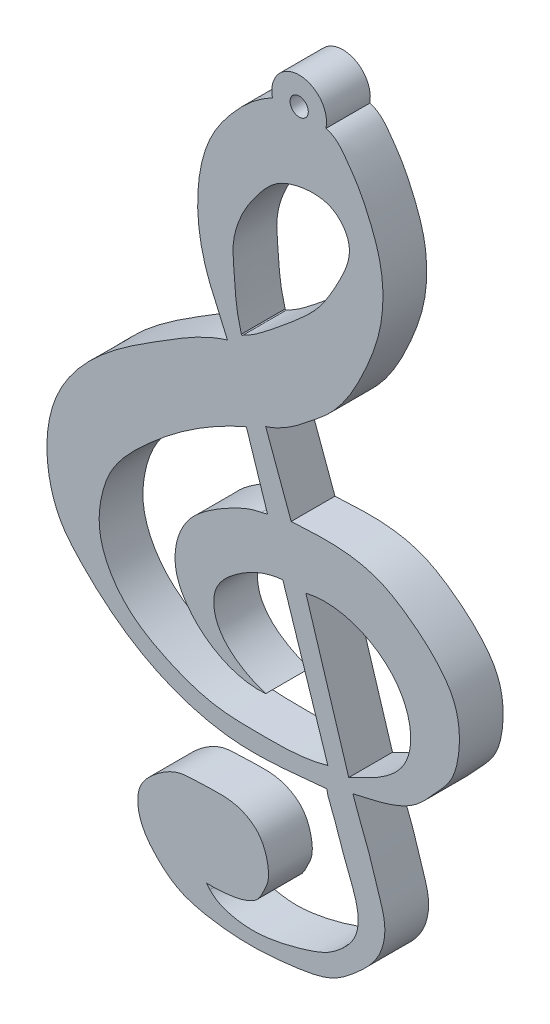
from build123d import *

# Parameters (mm, degrees)
CROQUIS1_R              = 0.5
SALIENTE_EXTRUIR1_DEPTH = 2.4


with BuildPart() as part:
    # Croquis1 → Saliente-Extruir1 (new body)
    with BuildSketch(Plane.XY):
        with BuildLine():
            add(Edge.make_bspline(
                [(-73.382843904, 21.485172649), (-72.816279322, 21.352562277), (-72.290048161, 20.617939926), (-71.563359458, 19.572554368), (-70.955369846, 18.303271377), (-70.180325761, 16.279733813), (-70.210087208, 13.6244299), (-71.118438702, 11.274052597), (-72.034700283, 9.43128208), (-73.060953827, 8.093199889), (-74.176463418, 7.211487575), (-75.245307097, 6.341435028), (-76.105343924, 5.854934057), (-76.688929455, 5.678784709)],
                knots=[0, 0, 0, 0, 0.082720072, 0.13560082, 0.197595917, 0.299487219, 0.46892434, 0.591754444, 0.687028642, 0.786865301, 0.848882337, 0.906336095, 1, 1, 1, 1], degree=3))
            Line((-76.688929455, 5.678784709), (-75.288653219, 1.867168619))
            add(Edge.make_bspline(
                [(-75.288653219, 1.867168619), (-74.468411952, 1.908252334), (-72.872577878, 2.015461097), (-70.631463745, 1.675125729), (-68.810384606, 0.565616098), (-67.389820174, -0.62554349), (-66.153734293, -2.256742458), (-65.96167945, -4.235010195), (-66.365441771, -6.009358939), (-67.459170254, -7.148174835), (-68.270466433, -8.123187694), (-69.854703917, -8.959771389), (-71.054207735, -9.166320913), (-71.906140878, -9.374564164)],
                knots=[0, 0, 0, 0, 0.11762295, 0.230289999, 0.317392698, 0.419586807, 0.496456837, 0.603597023, 0.693697186, 0.746523704, 0.827441455, 0.873617317, 1, 1, 1, 1], degree=3))
            add(Edge.make_bspline(
                [(-71.906140878, -9.374564164), (-71.61278094, -10.266839308), (-71.036756395, -11.553098269), (-70.528271485, -13.35950605), (-70.000664218, -14.794214547), (-70.38948534, -16.535052776), (-71.615071455, -17.699585086), (-73.060823598, -18.884419966), (-74.955161604, -19.19978755), (-77.241867683, -19.438869557), (-79.443104395, -19.317828204), (-81.433845047, -18.830999441), (-82.464748145, -17.980329563), (-83.140965101, -17.252480478), (-83.593955092, -16.480808011), (-83.752954974, -15.617546025), (-83.608641776, -14.78603997), (-83.194756323, -14.263514026), (-82.702884853, -13.823597136), (-82.179262793, -13.441681166), (-81.432137939, -13.092921965), (-80.517138878, -13.064254835), (-79.492506239, -13.016435402), (-78.279139352, -13.020538301), (-77.016213715, -13.666355282), (-76.555165276, -14.862084339), (-76.488557331, -15.83888893), (-76.815315899, -16.458860603), (-77.065125243, -17.020204619), (-77.742898732, -17.401740743), (-78.706718276, -17.603569236), (-79.482690885, -17.645040657), (-79.925056233, -17.629067046)],
                knots=[0, 0, 0, 0, 0.074805241, 0.11132212, 0.149630483, 0.194577694, 0.242981274, 0.281554535, 0.341328008, 0.390461965, 0.465398944, 0.516027146, 0.549472808, 0.569857733, 0.595053118, 0.619442754, 0.638197686, 0.660324416, 0.670723298, 0.690791225, 0.711746454, 0.73503389, 0.762613743, 0.793710312, 0.830998489, 0.86650762, 0.890979006, 0.905817433, 0.921675854, 0.938569682, 0.964778851, 1, 1, 1, 1], degree=3))
            add(Edge.make_bspline(
                [(-79.745792871, -17.851802825), (-79.925056233, -17.629067046)],
                knots=[0, 0, 1, 1], degree=1))
            add(Edge.make_bspline(
                [(-79.745792871, -17.851802825), (-79.377728082, -18.250457197), (-78.598905688, -18.510175961), (-77.445529422, -18.641537901), (-76.334832164, -18.54753779), (-75.193190702, -18.291470417), (-74.157420098, -17.982791531), (-73.328642935, -17.655936573), (-72.674800508, -17.19664297), (-72.136943705, -16.684677178), (-71.725059461, -16.078199587), (-71.557910168, -15.250749341), (-71.729283252, -14.277038523), (-72.075975491, -13.411558538), (-72.37751376, -12.660176729), (-72.546628338, -12.092589849), (-72.748229841, -11.588348302), (-72.895787934, -11.112644121), (-73.065295019, -10.700797712), (-73.235237824, -10.283342723), (-73.317254276, -10.026629889), (-73.326078886, -9.853276729)],
                knots=[0, 0, 0, 0, 0.100297216, 0.155435072, 0.224439636, 0.315020887, 0.381826218, 0.433978194, 0.486800826, 0.535484251, 0.577523687, 0.626710452, 0.694737543, 0.765895596, 0.807411146, 0.851576548, 0.88054523, 0.912596844, 0.948032108, 0.966788769, 1, 1, 1, 1], degree=3))
            add(Edge.make_bspline(
                [(-73.326078886, -9.853276729), (-74.979679959, -9.995751786), (-78.452282633, -10.49535985), (-83.388178533, -8.914488142), (-86.275432814, -6.495055205), (-87.957194856, -4.564365563), (-88.570288982, -2.996611158), (-88.775793899, -1.013821722), (-88.306004497, 1.729575325), (-85.949537881, 4.676575), (-82.425763739, 6.869714587), (-80.045029758, 8.359671299), (-78.783962186, 8.735087678)],
                knots=[0, 0, 0, 0, 0.144810891, 0.29982304, 0.43227727, 0.467632746, 0.520861501, 0.574899367, 0.63945409, 0.757272263, 0.88708928, 1, 1, 1, 1], degree=3))
            add(Edge.make_bspline(
                [(-78.783962186, 8.735087678), (-79.148845445, 9.634457766), (-80.225036896, 11.646609291), (-80.612874405, 14.950152713), (-79.907852199, 17.82628115), (-78.379717416, 19.921328754), (-77.201516961, 21.020487171), (-76.3154098, 21.464690957)],
                knots=[0, 0, 0, 0, 0.201335738, 0.468683326, 0.668300446, 0.798365415, 1, 1, 1, 1], degree=3))
            ThreePointArc((-76.3154098, 21.464690957), (-74.861810481, 23.290972059), (-73.382843904, 21.485172649))
        make_face()
        with Locations((-74.851334403, 21.791008643)):
            Circle(CROQUIS1_R, mode=Mode.SUBTRACT)
        with BuildLine():
            Line((-74.484460646, -1.133595475), (-72.133027249, -8.716968179))
            add(Edge.make_bspline(
                [(-74.484460646, -1.133595475), (-73.283378869, -0.850339229), (-71.440115738, -1.186045151), (-69.63352513, -2.610213082), (-68.835374903, -3.973046003), (-68.644563627, -5.376781633), (-69.097791243, -6.878034458), (-70.443842904, -7.955321849), (-71.594543517, -8.436745129), (-72.133027249, -8.716968179)],
                knots=[0, 0, 0, 0, 0.278394154, 0.399126556, 0.515243262, 0.629976033, 0.711946034, 0.862107141, 1, 1, 1, 1], degree=3))
        make_face(mode=Mode.SUBTRACT)
        with BuildLine():
            add(Edge.make_bspline(
                [(-77.928016672, 9.39589872), (-77.977009898, 9.316591026), (-78.022202288, 9.39589872)],
                knots=[0, 0, 0, 1, 1, 1], degree=2))
            add(Edge.make_bspline(
                [(-78.022202288, 9.39589872), (-78.112248491, 9.743130089), (-78.284610236, 10.407782258), (-78.36421323, 11.409395561), (-78.43433762, 12.340152669), (-78.512865884, 13.222993811), (-78.400129242, 13.997240727), (-78.145886099, 14.774699767), (-77.782315961, 15.558796545), (-77.239268592, 16.313589804), (-76.698081348, 17.018136895), (-75.948448577, 17.679765585), (-74.922434231, 18.019394979), (-73.923097777, 18.108525469), (-72.826532687, 17.872003144), (-72.062827891, 16.965972459), (-72.102821748, 15.783989767), (-72.52046451, 14.856380567), (-73.10790887, 13.752968837), (-73.778471189, 12.706556273), (-74.678093213, 11.851215915), (-75.618461258, 11.048901475), (-76.628439152, 10.234767882), (-77.424220679, 9.64031082), (-77.86765592, 9.425182197), (-77.928016672, 9.39589872)],
                knots=[0, 0, 0, 0, 0.046234465, 0.088499601, 0.129376126, 0.166981464, 0.202560649, 0.229435641, 0.272508236, 0.313509199, 0.349201554, 0.387286028, 0.440602524, 0.485479344, 0.515571404, 0.583511224, 0.614581517, 0.664465849, 0.712996668, 0.776704411, 0.823500625, 0.87268466, 0.936376551, 0.991339526, 1, 1, 1, 1], degree=3))
        make_face(mode=Mode.SUBTRACT)
        with BuildLine():
            Line((-75.748356097, -1.133595475), (-73.27935103, -8.716968179))
            add(Edge.make_bspline(
                [(-73.27935103, -8.716968179), (-74.54403941, -9.099328125), (-76.597852728, -9.085833404), (-79.644615755, -9.068104931), (-81.932302943, -8.226273805), (-83.957404242, -7.110551081), (-85.273526187, -5.621380732), (-85.914909067, -3.853044747), (-85.759925302, -2.201384209), (-85.282619327, -0.736042917), (-84.392643233, 0.456217849), (-83.27080941, 1.539666913), (-81.207549469, 3.314419204), (-79.282403907, 4.472508042), (-77.747782265, 5.134297209)],
                knots=[0, 0, 0, 0, 0.140602397, 0.223478455, 0.328347819, 0.401004637, 0.472812394, 0.539192635, 0.598886041, 0.649529088, 0.70484218, 0.758150444, 0.818924333, 1, 1, 1, 1], degree=3))
            Line((-77.747782265, 5.134297209), (-76.583774396, 1.559130182))
            add(Edge.make_bspline(
                [(-76.583774396, 1.559130182), (-76.924072795, 1.482374179)],
                knots=[0, 0, 1, 1], degree=1))
            add(Edge.make_bspline(
                [(-76.688929455, -7.012178967), (-77.779962606, -7.101137668), (-79.354199759, -6.611511351), (-80.90825158, -5.19158372), (-81.724995865, -3.79418853), (-81.664670946, -2.150791159), (-80.978762427, -0.807113786), (-80.041282643, -0.014701178), (-79.235120023, 0.503541817), (-78.26137141, 1.051323643), (-77.500345123, 1.381049705), (-76.924072795, 1.482374179)],
                knots=[0, 0, 0, 0, 0.22965919, 0.335098219, 0.44680271, 0.56432709, 0.670369882, 0.760787276, 0.823624202, 0.875763436, 1, 1, 1, 1], degree=3))
            add(Edge.make_bspline(
                [(-76.688929455, -7.012178967), (-77.740334836, -6.669763356), (-79.493284206, -5.687330151), (-79.609713646, -3.253547132), (-78.048029923, -1.823215334), (-76.690901104, -1.21666721), (-75.748356097, -1.133595475)],
                knots=[0, 0, 0, 0, 0.383378054, 0.51727079, 0.709392586, 1, 1, 1, 1], degree=3))
        make_face(mode=Mode.SUBTRACT)
    extrude(amount=SALIENTE_EXTRUIR1_DEPTH)


solid = part.part
